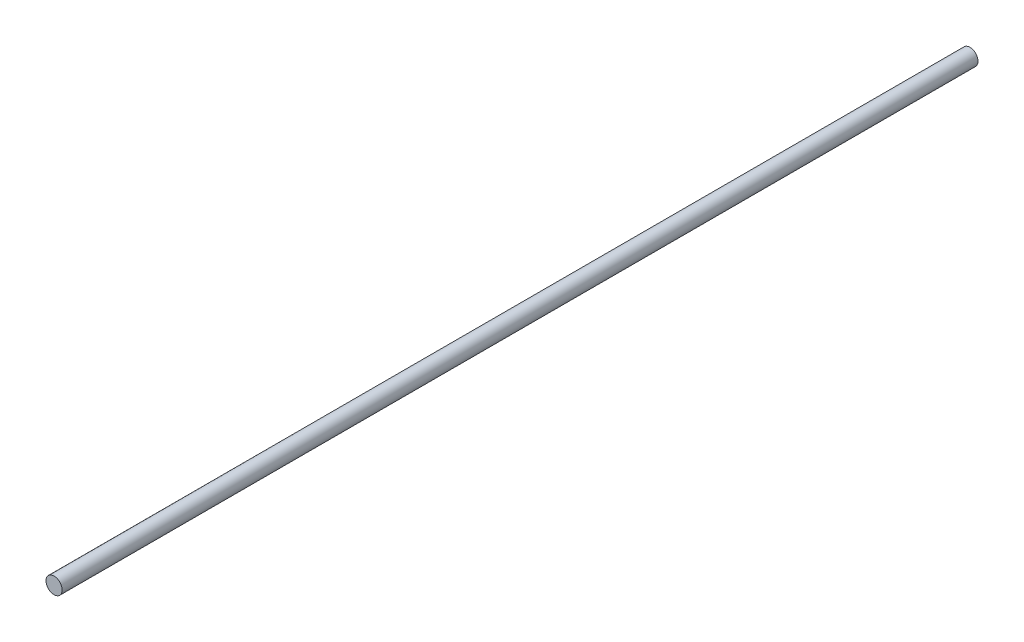
from build123d import *

# Parameters (mm, degrees)
SKETCH1_R           = 1.5
BOSS_EXTRUDE1_DEPTH = 85


with BuildPart() as part:
    # Sketch1 → Boss-Extrude1 (new body, symmetric)
    with BuildSketch(Plane.XY):
        Circle(SKETCH1_R)
    extrude(amount=BOSS_EXTRUDE1_DEPTH, both=True)


solid = part.part
